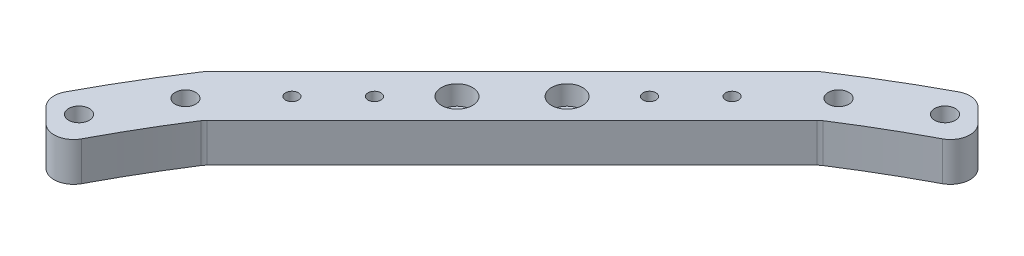
from build123d import *

# Parameters (mm, degrees)
SKETCH_1_R               = 275
SKETCH_1_R_2             = 255
EXTRUDE_1_DEPTH          = 10
EXTRUDE_2_DEPTH          = 10
SKETCH_8_R               = 2.65
SKETCH_8_R_2             = 1.65
SKETCH_8_R_3             = 2.15
CUT_EXTRUDE_1_DEPTH      = 21
SKETCH_9_OUTSIDE_W       = 707.614
SKETCH_9_OUTSIDE_H       = 707.614
CUT_EXTRUDE_2_DEPTH      = 21
SKETCH_10_W              = 777.504065726
SKETCH_10_H              = 20
CUT_EXTRUDE_3_DEPTH      = 276
CUT_EXTRUDE_3_DEPTH_BACK = 276
EXTRUDE_3_DEPTH          = 10
CUT_EXTRUDE_4_DEPTH      = 10
SKETCH_13_R              = 1.65
CUT_EXTRUDE_5_DEPTH      = 10
CUT_EXTRUDE_START        = -10
SKETCH_14_R              = 4
CUT_EXTRUDE_6_DEPTH      = 5
FILLET_1_R               = 5


with BuildPart() as part:
    # 草图1 → 凸台-拉伸1 (new body)
    with BuildSketch(Plane(origin=(0, 0, 0), x_dir=(1, 0, 0), z_dir=(0, 1, 0))):
        Circle(SKETCH_1_R)
        Circle(SKETCH_1_R_2, mode=Mode.SUBTRACT)
    extrude(amount=EXTRUDE_1_DEPTH)

    # 草图10 → 切除-拉伸3 (cut, two sides)
    with BuildSketch(Plane.XY) as cut_extrude_3_sk:
        Rectangle(SKETCH_10_W, SKETCH_10_H)
    extrude(amount=CUT_EXTRUDE_3_DEPTH, mode=Mode.SUBTRACT)
    extrude(cut_extrude_3_sk.sketch, amount=-CUT_EXTRUDE_3_DEPTH_BACK, mode=Mode.SUBTRACT)


with BuildPart() as body_2:
    # 草图2 → 凸台-拉伸2 (new body)
    with BuildSketch(Plane(origin=(0, 10, 0), x_dir=(1, 0, 0), z_dir=(0, 1, 0))):
        with BuildLine():
            Line((-110.525139894, 257.262887824), (-25.423255477, 200))
            Line((-25.423255477, 200), (0, 200))
            Line((0, 200), (25.423255477, 200))
            Line((25.423255477, 200), (110.525139894, 257.262887824))
            ThreePointArc((110.525139894, 257.262887824), (197.989898732, 197.989898732), (257.262887824, 110.525139894))
            Line((257.262887824, 110.525139894), (200, 25.423255477))
            Line((200, 25.423255477), (200, 0))
            Line((200, 0), (200, -25.423255477))
            Line((200, -25.423255477), (257.262887824, -110.525139894))
            ThreePointArc((257.262887824, -110.525139894), (197.989898732, -197.989898732), (110.525139894, -257.262887824))
            Line((110.525139894, -257.262887824), (25.423255477, -200))
            Line((25.423255477, -200), (0, -200))
            Line((0, -200), (-25.423255477, -200))
            Line((-25.423255477, -200), (-110.525139894, -257.262887824))
            ThreePointArc((-110.525139894, -257.262887824), (-197.989898732, -197.989898732), (-257.262887824, -110.525139894))
            Line((-257.262887824, -110.525139894), (-200, -25.423255477))
            Line((-200, -25.423255477), (-200, 25.423255477))
            Line((-200, 25.423255477), (-257.262887824, 110.525139894))
            ThreePointArc((-257.262887824, 110.525139894), (-197.989898732, 197.989898732), (-110.525139894, 257.262887824))
        make_face()
        with BuildLine():
            Line((0, 185), (30, 185))
            Line((30, 185), (111.993839361, 240.171563565))
            ThreePointArc((111.993839361, 240.171563565), (187.383297014, 187.383297014), (240.171563565, 111.993839361))
            Line((240.171563565, 111.993839361), (185, 30))
            Line((185, 30), (185, 0))
            Line((185, 0), (185, -30))
            Line((185, -30), (240.171563565, -111.993839361))
            ThreePointArc((240.171563565, -111.993839361), (187.383297014, -187.383297014), (111.993839361, -240.171563565))
            Line((111.993839361, -240.171563565), (30, -185))
            Line((30, -185), (0, -185))
            Line((0, -185), (-30, -185))
            Line((-30, -185), (-111.993839361, -240.171563565))
            ThreePointArc((-111.993839361, -240.171563565), (-187.383297014, -187.383297014), (-240.171563565, -111.993839361))
            Line((-240.171563565, -111.993839361), (-185, -30))
            Line((-185, -30), (-185, 30))
            Line((-185, 30), (-240.171563565, 111.993839361))
            ThreePointArc((-240.171563565, 111.993839361), (-187.383297014, 187.383297014), (-111.993839361, 240.171563565))
            Line((-111.993839361, 240.171563565), (-30, 185))
            Line((-30, 185), (0, 185))
        make_face(mode=Mode.SUBTRACT)
    extrude(amount=EXTRUDE_2_DEPTH)

    # 草图8 → 切除-拉伸1 (cut, through all)
    with BuildSketch(Plane(origin=(0, 20, 0), x_dir=(1, 0, 0), z_dir=(0, 1, 0))):
        with Locations((-10, 192.5)):
            Circle(SKETCH_8_R)
        with Locations((10, 192.5)):
            Circle(SKETCH_8_R)
        with Locations((-10, -192.5)):
            Circle(SKETCH_8_R)
        with Locations((10, -192.5)):
            Circle(SKETCH_8_R)
        with Locations((192.5, 10)):
            Circle(SKETCH_8_R)
        with Locations((192.5, -10)):
            Circle(SKETCH_8_R)
        with Locations((-192.5, 10)):
            Circle(SKETCH_8_R)
        with Locations((-192.5, -10)):
            Circle(SKETCH_8_R)
        with Locations((-110.525139894, 248.223100485)):
            Circle(SKETCH_8_R_2)
        with Locations((-27.711627738, 192.5)):
            Circle(SKETCH_8_R_3)
        with Locations((-44.304938442, 203.665215623)):
            Circle(SKETCH_8_R_3)
        with Locations((-56.749921469, 212.03912734)):
            Circle(SKETCH_8_R_3)
        with Locations((-69.194904497, 220.413039057)):
            Circle(SKETCH_8_R_3)
        with Locations((-81.639887524, 228.786950774)):
            Circle(SKETCH_8_R_3)
        with Locations((-146.077022117, 230.028561882)):
            Circle(SKETCH_8_R)
        with Locations((-164.415519771, 217.299729706)):
            Circle(SKETCH_8_R)
        with Locations((-183.638937552, 201.316607082)):
            Circle(SKETCH_8_R)
        with Locations((-201.316607082, 183.638937552)):
            Circle(SKETCH_8_R)
        with Locations((-217.299729706, 164.415519771)):
            Circle(SKETCH_8_R)
        with Locations((-230.028561882, 146.077022117)):
            Circle(SKETCH_8_R)
        with Locations((-128.811575358, 240.123330241)):
            Circle(SKETCH_8_R)
        with Locations((-240.123330241, 128.811575358)):
            Circle(SKETCH_8_R)
        with Locations((-228.786950774, 81.639887524)):
            Circle(SKETCH_8_R_3)
        with Locations((-220.413039057, 69.194904497)):
            Circle(SKETCH_8_R_3)
        with Locations((-212.03912734, 56.749921469)):
            Circle(SKETCH_8_R_3)
        with Locations((-203.665215623, 44.304938442)):
            Circle(SKETCH_8_R_3)
        with Locations((-192.5, 27.711627738)):
            Circle(SKETCH_8_R_3)
        with Locations((-248.223100485, 110.525139894)):
            Circle(SKETCH_8_R_2)
        with Locations((192.5, 27.711627738)):
            Circle(SKETCH_8_R_3)
        with Locations((248.223100485, 110.525139894)):
            Circle(SKETCH_8_R_2)
        with Locations((203.665215623, 44.304938442)):
            Circle(SKETCH_8_R_3)
        with Locations((212.03912734, 56.749921469)):
            Circle(SKETCH_8_R_3)
        with Locations((220.413039057, 69.194904497)):
            Circle(SKETCH_8_R_3)
        with Locations((228.786950774, 81.639887524)):
            Circle(SKETCH_8_R_3)
        with Locations((240.123330241, 128.811575358)):
            Circle(SKETCH_8_R)
        with Locations((230.028561882, 146.077022117)):
            Circle(SKETCH_8_R)
        with Locations((128.811575358, 240.123330241)):
            Circle(SKETCH_8_R)
        with Locations((201.316607082, 183.638937552)):
            Circle(SKETCH_8_R)
        with Locations((183.638937552, 201.316607082)):
            Circle(SKETCH_8_R)
        with Locations((164.415519771, 217.299729706)):
            Circle(SKETCH_8_R)
        with Locations((146.077022117, 230.028561882)):
            Circle(SKETCH_8_R)
        with Locations((81.639887524, 228.786950774)):
            Circle(SKETCH_8_R_3)
        with Locations((69.194904497, 220.413039057)):
            Circle(SKETCH_8_R_3)
        with Locations((56.749921469, 212.03912734)):
            Circle(SKETCH_8_R_3)
        with Locations((44.304938442, 203.665215623)):
            Circle(SKETCH_8_R_3)
        with Locations((110.525139894, 248.223100485)):
            Circle(SKETCH_8_R_2)
        with Locations((27.711627738, 192.5)):
            Circle(SKETCH_8_R_3)
        with Locations((217.299729706, 164.415519771)):
            Circle(SKETCH_8_R)
    extrude(amount=-CUT_EXTRUDE_1_DEPTH, mode=Mode.SUBTRACT)

    # 草图9 outside → 切除-拉伸2 (cut, through all)
    with BuildSketch(Plane(origin=(0, 20, 0), x_dir=(1, 0, 0), z_dir=(0, 1, 0))):
        Rectangle(SKETCH_9_OUTSIDE_W, SKETCH_9_OUTSIDE_H)
        with BuildLine():
            Line((-128.813345638, 248.610381894), (-117.653354647, 237.450390904))
            ThreePointArc((-117.653354647, 237.450390904), (-187.383297014, 187.383297014), (-237.450390904, 117.653354647))
            Line((-237.450390904, 117.653354647), (-248.610381894, 128.813345638))
            ThreePointArc((-248.610381894, 128.813345638), (-197.989898732, 197.989898732), (-128.813345638, 248.610381894))
        make_face(mode=Mode.SUBTRACT)
    extrude(amount=-CUT_EXTRUDE_2_DEPTH, mode=Mode.SUBTRACT)

    # 草图11 → 凸台-拉伸3 (add)
    with BuildSketch(Plane(origin=(0, 20, 0), x_dir=(1, 0, 0), z_dir=(0, 1, 0))):
        Polygon((-222.749556316, 143.553596823), (-233.587670194, 154.391710701), (-154.391710701, 233.587670194), (-143.553596823, 222.749556316), align=None)
    extrude(amount=-EXTRUDE_3_DEPTH)

    # 草图12 → 切除-拉伸4 (cut)
    with BuildSketch(Plane(origin=(0, 20, 0), x_dir=(1, 0, 0), z_dir=(0, 1, 0))):
        with BuildLine():
            Line((-233.587670194, 154.391710701), (-154.391710701, 233.587670194))
            ThreePointArc((-154.391710701, 233.587670194), (-197.989898732, 197.989898732), (-233.587670194, 154.391710701))
        make_face()
    extrude(amount=-CUT_EXTRUDE_4_DEPTH, mode=Mode.SUBTRACT)

    # 草图13 → 切除-拉伸5 (cut)
    with BuildSketch(Plane(origin=(0, 20, 0), x_dir=(1, 0, 0), z_dir=(0, 1, 0))):
        with Locations((-195.525945241, 181.383809617)):
            Circle(SKETCH_13_R)
        with Locations((-206.132546958, 170.777207899)):
            Circle(SKETCH_13_R)
        with Locations((-216.739148676, 160.170606181)):
            Circle(SKETCH_13_R)
        with Locations((-181.383809617, 195.525945241)):
            Circle(SKETCH_13_R)
        with Locations((-170.777207899, 206.132546958)):
            Circle(SKETCH_13_R)
        with Locations((-160.170606181, 216.739148676)):
            Circle(SKETCH_13_R)
    extrude(amount=-CUT_EXTRUDE_5_DEPTH, mode=Mode.SUBTRACT)

    # 草图14 → 切除-拉伸6 (cut)
    with BuildSketch(Plane.XZ.offset(-10).offset(CUT_EXTRUDE_START)):
        with Locations((-181.383809617, -195.525945241)):
            Circle(SKETCH_14_R)
        with Locations((-195.525945241, -181.383809617)):
            Circle(SKETCH_14_R)
    extrude(amount=CUT_EXTRUDE_6_DEPTH, mode=Mode.SUBTRACT)

    # 圆角1
    fillet_1_edges = [body_2.edges().sort_by_distance(p)[0] for p in [
        (-237.450390904, 15, -117.653354647),
        (-117.653354647, 15, -237.450390904),
        (-128.813345638, 15, -248.610381894),
        (-248.610381894, 15, -128.813345638),
        (-143.553596823, 15, -222.749556316),
        (-222.749556316, 15, -143.553596823),
        (-154.391710701, 15, -233.587670194),
        (-233.587670194, 15, -154.391710701),
    ]]
    fillet(fillet_1_edges, radius=FILLET_1_R)


solid = body_2.part
